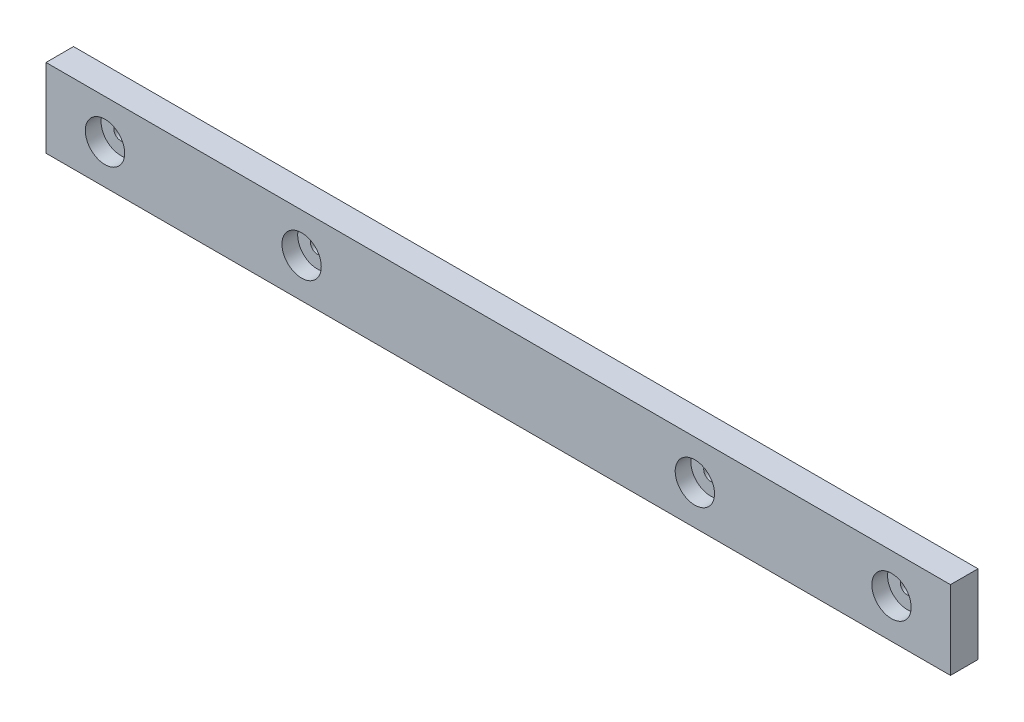
from build123d import *

# Parameters (mm, degrees)
SKETCH1_W           = 230
SKETCH1_H           = 20
BOSS_EXTRUDE1_DEPTH = 7
SKETCH2_R           = 1.75
CUT_EXTRUDE1_DEPTH  = 8
SKETCH3_R           = 5
CUT_EXTRUDE2_DEPTH  = 4


with BuildPart() as part:
    # Sketch1 → Boss-Extrude1 (new body)
    with BuildSketch(Plane.XY):
        Rectangle(SKETCH1_W, SKETCH1_H)
    extrude(amount=BOSS_EXTRUDE1_DEPTH)

    # Sketch2 → Cut-Extrude1 (cut, through all)
    with BuildSketch(Plane.XY.offset(7)):
        with Locations((-100, 0)):
            Circle(SKETCH2_R)
        with Locations((100, 0)):
            Circle(SKETCH2_R)
        with Locations((50, 0)):
            Circle(SKETCH2_R)
        with Locations((-50, 0)):
            Circle(SKETCH2_R)
    extrude(amount=-CUT_EXTRUDE1_DEPTH, mode=Mode.SUBTRACT)

    # Sketch3 → Cut-Extrude2 (cut)
    with BuildSketch(Plane.XY.offset(7)):
        with Locations((-100, 0)):
            Circle(SKETCH3_R)
        with Locations((-50, 0)):
            Circle(SKETCH3_R)
        with Locations((50, 0)):
            Circle(SKETCH3_R)
        with Locations((100, 0)):
            Circle(SKETCH3_R)
    extrude(amount=-CUT_EXTRUDE2_DEPTH, mode=Mode.SUBTRACT)


solid = part.part
